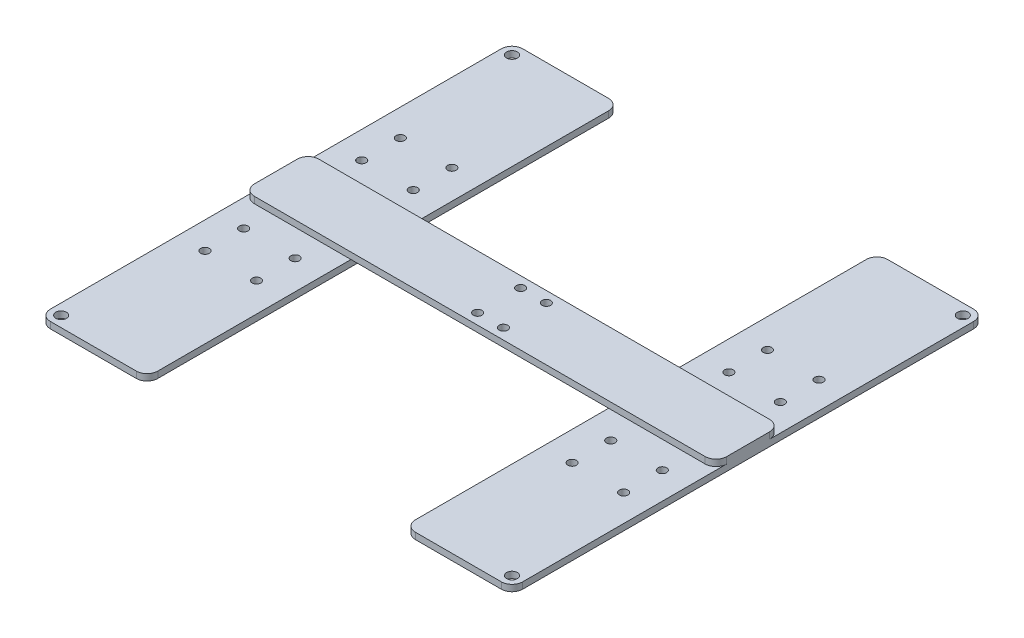
from build123d import *

# Parameters (mm, degrees)
SKETCH1_W           = 220
SKETCH1_H           = 30
BOSS_EXTRUDE1_DEPTH = 3
SKETCH2_W           = 50
SKETCH2_H           = 220
BOSS_EXTRUDE2_DEPTH = 3
SKETCH3_R           = 2.5
CUT_EXTRUDE1_DEPTH  = 3
FILLET1_R           = 5
CUT_EXTRUDE2_REACH  = 5
SKETCH4_R           = 2
CUT_EXTRUDE3_REACH  = 8
SKETCH5_R           = 2


with BuildPart() as part:
    # Sketch1 → Boss-Extrude1 (new body)
    with BuildSketch(Plane(origin=(0, 0, 0), x_dir=(1, 0, 0), z_dir=(0, 1, 0))):
        Rectangle(SKETCH1_W, SKETCH1_H)
    extrude(amount=BOSS_EXTRUDE1_DEPTH)

    # Sketch2 → Boss-Extrude2 (add)
    with BuildSketch(Plane.XZ):
        with Locations((-85, 0)):
            Rectangle(SKETCH2_W, SKETCH2_H)
        with Locations((85, 0)):
            Rectangle(SKETCH2_W, SKETCH2_H)
    extrude(amount=BOSS_EXTRUDE2_DEPTH)

    # Sketch3 → Cut-Extrude1 (cut)
    with BuildSketch(Plane(origin=(0, 0, 0), x_dir=(1, 0, 0), z_dir=(0, 1, 0))):
        with Locations((-105, 105)):
            Circle(SKETCH3_R)
        with Locations((105, 105)):
            Circle(SKETCH3_R)
        with Locations((105, -105)):
            Circle(SKETCH3_R)
        with Locations((-105, -105)):
            Circle(SKETCH3_R)
    extrude(amount=-CUT_EXTRUDE1_DEPTH, mode=Mode.SUBTRACT)

    # Fillet1
    fillet1_edges = [part.edges().sort_by_distance(p)[0] for p in [
        (-60, -1.5, -110),
        (-60, -1.5, 110),
        (-110, -1.5, 110),
        (-110, -1.5, -110),
        (110, -1.5, -110),
        (110, -1.5, 110),
        (60, -1.5, 110),
        (60, -1.5, -110),
        (110, 1.5, 15),
        (-110, 1.5, 15),
        (-110, 1.5, -15),
        (110, 1.5, -15),
    ]]
    fillet(fillet1_edges, radius=FILLET1_R)

    # Sketch4 → Cut-Extrude2 (cut, up to next)
    with BuildSketch(Plane(origin=(0, 0, 0), x_dir=(1, 0, 0), z_dir=(0, 1, 0)), mode=Mode.PRIVATE) as cut_extrude2_sk1:
        with Locations((-97.5, 27.5)):
            Circle(SKETCH4_R)
    cut_extrude2_tool1 = extrude(cut_extrude2_sk1.sketch, amount=-CUT_EXTRUDE2_REACH, mode=Mode.PRIVATE) & part.part
    add(cut_extrude2_tool1.solids().sort_by_distance((-97.5, 0, -27.5))[0], mode=Mode.SUBTRACT)
    # Sketch4 → Cut-Extrude2 (cut, up to next)
    with BuildSketch(Plane(origin=(0, 0, 0), x_dir=(1, 0, 0), z_dir=(0, 1, 0)), mode=Mode.PRIVATE) as cut_extrude2_sk2:
        with Locations((-73.5, 27.5)):
            Circle(SKETCH4_R)
    cut_extrude2_tool2 = extrude(cut_extrude2_sk2.sketch, amount=-CUT_EXTRUDE2_REACH, mode=Mode.PRIVATE) & part.part
    add(cut_extrude2_tool2.solids().sort_by_distance((-73.5, 0, -27.5))[0], mode=Mode.SUBTRACT)
    # Sketch4 → Cut-Extrude2 (cut, up to next)
    with BuildSketch(Plane(origin=(0, 0, 0), x_dir=(1, 0, 0), z_dir=(0, 1, 0)), mode=Mode.PRIVATE) as cut_extrude2_sk3:
        with Locations((-73.5, 45.5)):
            Circle(SKETCH4_R)
    cut_extrude2_tool3 = extrude(cut_extrude2_sk3.sketch, amount=-CUT_EXTRUDE2_REACH, mode=Mode.PRIVATE) & part.part
    add(cut_extrude2_tool3.solids().sort_by_distance((-73.5, 0, -45.5))[0], mode=Mode.SUBTRACT)
    # Sketch4 → Cut-Extrude2 (cut, up to next)
    with BuildSketch(Plane(origin=(0, 0, 0), x_dir=(1, 0, 0), z_dir=(0, 1, 0)), mode=Mode.PRIVATE) as cut_extrude2_sk4:
        with Locations((-97.5, 45.5)):
            Circle(SKETCH4_R)
    cut_extrude2_tool4 = extrude(cut_extrude2_sk4.sketch, amount=-CUT_EXTRUDE2_REACH, mode=Mode.PRIVATE) & part.part
    add(cut_extrude2_tool4.solids().sort_by_distance((-97.5, 0, -45.5))[0], mode=Mode.SUBTRACT)
    # Sketch4 → Cut-Extrude2 (cut, up to next)
    with BuildSketch(Plane(origin=(0, 0, 0), x_dir=(1, 0, 0), z_dir=(0, 1, 0)), mode=Mode.PRIVATE) as cut_extrude2_sk5:
        with Locations((97.5, 45.5)):
            Circle(SKETCH4_R)
    cut_extrude2_tool5 = extrude(cut_extrude2_sk5.sketch, amount=-CUT_EXTRUDE2_REACH, mode=Mode.PRIVATE) & part.part
    add(cut_extrude2_tool5.solids().sort_by_distance((97.5, 0, -45.5))[0], mode=Mode.SUBTRACT)
    # Sketch4 → Cut-Extrude2 (cut, up to next)
    with BuildSketch(Plane(origin=(0, 0, 0), x_dir=(1, 0, 0), z_dir=(0, 1, 0)), mode=Mode.PRIVATE) as cut_extrude2_sk6:
        with Locations((73.5, 45.5)):
            Circle(SKETCH4_R)
    cut_extrude2_tool6 = extrude(cut_extrude2_sk6.sketch, amount=-CUT_EXTRUDE2_REACH, mode=Mode.PRIVATE) & part.part
    add(cut_extrude2_tool6.solids().sort_by_distance((73.5, 0, -45.5))[0], mode=Mode.SUBTRACT)
    # Sketch4 → Cut-Extrude2 (cut, up to next)
    with BuildSketch(Plane(origin=(0, 0, 0), x_dir=(1, 0, 0), z_dir=(0, 1, 0)), mode=Mode.PRIVATE) as cut_extrude2_sk7:
        with Locations((73.5, 27.5)):
            Circle(SKETCH4_R)
    cut_extrude2_tool7 = extrude(cut_extrude2_sk7.sketch, amount=-CUT_EXTRUDE2_REACH, mode=Mode.PRIVATE) & part.part
    add(cut_extrude2_tool7.solids().sort_by_distance((73.5, 0, -27.5))[0], mode=Mode.SUBTRACT)
    # Sketch4 → Cut-Extrude2 (cut, up to next)
    with BuildSketch(Plane(origin=(0, 0, 0), x_dir=(1, 0, 0), z_dir=(0, 1, 0)), mode=Mode.PRIVATE) as cut_extrude2_sk8:
        with Locations((97.5, 27.5)):
            Circle(SKETCH4_R)
    cut_extrude2_tool8 = extrude(cut_extrude2_sk8.sketch, amount=-CUT_EXTRUDE2_REACH, mode=Mode.PRIVATE) & part.part
    add(cut_extrude2_tool8.solids().sort_by_distance((97.5, 0, -27.5))[0], mode=Mode.SUBTRACT)
    # Sketch4 → Cut-Extrude2 (cut, up to next)
    with BuildSketch(Plane(origin=(0, 0, 0), x_dir=(1, 0, 0), z_dir=(0, 1, 0)), mode=Mode.PRIVATE) as cut_extrude2_sk9:
        with Locations((97.5, -27.5)):
            Circle(SKETCH4_R)
    cut_extrude2_tool9 = extrude(cut_extrude2_sk9.sketch, amount=-CUT_EXTRUDE2_REACH, mode=Mode.PRIVATE) & part.part
    add(cut_extrude2_tool9.solids().sort_by_distance((97.5, 0, 27.5))[0], mode=Mode.SUBTRACT)
    # Sketch4 → Cut-Extrude2 (cut, up to next)
    with BuildSketch(Plane(origin=(0, 0, 0), x_dir=(1, 0, 0), z_dir=(0, 1, 0)), mode=Mode.PRIVATE) as cut_extrude2_sk10:
        with Locations((73.5, -27.5)):
            Circle(SKETCH4_R)
    cut_extrude2_tool10 = extrude(cut_extrude2_sk10.sketch, amount=-CUT_EXTRUDE2_REACH, mode=Mode.PRIVATE) & part.part
    add(cut_extrude2_tool10.solids().sort_by_distance((73.5, 0, 27.5))[0], mode=Mode.SUBTRACT)
    # Sketch4 → Cut-Extrude2 (cut, up to next)
    with BuildSketch(Plane(origin=(0, 0, 0), x_dir=(1, 0, 0), z_dir=(0, 1, 0)), mode=Mode.PRIVATE) as cut_extrude2_sk11:
        with Locations((73.5, -45.5)):
            Circle(SKETCH4_R)
    cut_extrude2_tool11 = extrude(cut_extrude2_sk11.sketch, amount=-CUT_EXTRUDE2_REACH, mode=Mode.PRIVATE) & part.part
    add(cut_extrude2_tool11.solids().sort_by_distance((73.5, 0, 45.5))[0], mode=Mode.SUBTRACT)
    # Sketch4 → Cut-Extrude2 (cut, up to next)
    with BuildSketch(Plane(origin=(0, 0, 0), x_dir=(1, 0, 0), z_dir=(0, 1, 0)), mode=Mode.PRIVATE) as cut_extrude2_sk12:
        with Locations((97.5, -45.5)):
            Circle(SKETCH4_R)
    cut_extrude2_tool12 = extrude(cut_extrude2_sk12.sketch, amount=-CUT_EXTRUDE2_REACH, mode=Mode.PRIVATE) & part.part
    add(cut_extrude2_tool12.solids().sort_by_distance((97.5, 0, 45.5))[0], mode=Mode.SUBTRACT)
    # Sketch4 → Cut-Extrude2 (cut, up to next)
    with BuildSketch(Plane(origin=(0, 0, 0), x_dir=(1, 0, 0), z_dir=(0, 1, 0)), mode=Mode.PRIVATE) as cut_extrude2_sk13:
        with Locations((-97.5, -45.5)):
            Circle(SKETCH4_R)
    cut_extrude2_tool13 = extrude(cut_extrude2_sk13.sketch, amount=-CUT_EXTRUDE2_REACH, mode=Mode.PRIVATE) & part.part
    add(cut_extrude2_tool13.solids().sort_by_distance((-97.5, 0, 45.5))[0], mode=Mode.SUBTRACT)
    # Sketch4 → Cut-Extrude2 (cut, up to next)
    with BuildSketch(Plane(origin=(0, 0, 0), x_dir=(1, 0, 0), z_dir=(0, 1, 0)), mode=Mode.PRIVATE) as cut_extrude2_sk14:
        with Locations((-73.5, -45.5)):
            Circle(SKETCH4_R)
    cut_extrude2_tool14 = extrude(cut_extrude2_sk14.sketch, amount=-CUT_EXTRUDE2_REACH, mode=Mode.PRIVATE) & part.part
    add(cut_extrude2_tool14.solids().sort_by_distance((-73.5, 0, 45.5))[0], mode=Mode.SUBTRACT)
    # Sketch4 → Cut-Extrude2 (cut, up to next)
    with BuildSketch(Plane(origin=(0, 0, 0), x_dir=(1, 0, 0), z_dir=(0, 1, 0)), mode=Mode.PRIVATE) as cut_extrude2_sk15:
        with Locations((-73.5, -27.5)):
            Circle(SKETCH4_R)
    cut_extrude2_tool15 = extrude(cut_extrude2_sk15.sketch, amount=-CUT_EXTRUDE2_REACH, mode=Mode.PRIVATE) & part.part
    add(cut_extrude2_tool15.solids().sort_by_distance((-73.5, 0, 27.5))[0], mode=Mode.SUBTRACT)
    # Sketch4 → Cut-Extrude2 (cut, up to next)
    with BuildSketch(Plane(origin=(0, 0, 0), x_dir=(1, 0, 0), z_dir=(0, 1, 0)), mode=Mode.PRIVATE) as cut_extrude2_sk16:
        with Locations((-97.5, -27.5)):
            Circle(SKETCH4_R)
    cut_extrude2_tool16 = extrude(cut_extrude2_sk16.sketch, amount=-CUT_EXTRUDE2_REACH, mode=Mode.PRIVATE) & part.part
    add(cut_extrude2_tool16.solids().sort_by_distance((-97.5, 0, 27.5))[0], mode=Mode.SUBTRACT)

    # Sketch5 → Cut-Extrude3 (cut, up to next)
    with BuildSketch(Plane(origin=(0, 3, 0), x_dir=(1, 0, 0), z_dir=(0, 1, 0)), mode=Mode.PRIVATE) as cut_extrude3_sk1:
        with Locations((-6, 10)):
            Circle(SKETCH5_R)
    cut_extrude3_tool1 = extrude(cut_extrude3_sk1.sketch, amount=-CUT_EXTRUDE3_REACH, mode=Mode.PRIVATE) & part.part
    add(cut_extrude3_tool1.solids().sort_by_distance((-6, 3, -10))[0], mode=Mode.SUBTRACT)
    # Sketch5 → Cut-Extrude3 (cut, up to next)
    with BuildSketch(Plane(origin=(0, 3, 0), x_dir=(1, 0, 0), z_dir=(0, 1, 0)), mode=Mode.PRIVATE) as cut_extrude3_sk2:
        with Locations((6, 10)):
            Circle(SKETCH5_R)
    cut_extrude3_tool2 = extrude(cut_extrude3_sk2.sketch, amount=-CUT_EXTRUDE3_REACH, mode=Mode.PRIVATE) & part.part
    add(cut_extrude3_tool2.solids().sort_by_distance((6, 3, -10))[0], mode=Mode.SUBTRACT)
    # Sketch5 → Cut-Extrude3 (cut, up to next)
    with BuildSketch(Plane(origin=(0, 3, 0), x_dir=(1, 0, 0), z_dir=(0, 1, 0)), mode=Mode.PRIVATE) as cut_extrude3_sk3:
        with Locations((6, -10)):
            Circle(SKETCH5_R)
    cut_extrude3_tool3 = extrude(cut_extrude3_sk3.sketch, amount=-CUT_EXTRUDE3_REACH, mode=Mode.PRIVATE) & part.part
    add(cut_extrude3_tool3.solids().sort_by_distance((6, 3, 10))[0], mode=Mode.SUBTRACT)
    # Sketch5 → Cut-Extrude3 (cut, up to next)
    with BuildSketch(Plane(origin=(0, 3, 0), x_dir=(1, 0, 0), z_dir=(0, 1, 0)), mode=Mode.PRIVATE) as cut_extrude3_sk4:
        with Locations((-6, -10)):
            Circle(SKETCH5_R)
    cut_extrude3_tool4 = extrude(cut_extrude3_sk4.sketch, amount=-CUT_EXTRUDE3_REACH, mode=Mode.PRIVATE) & part.part
    add(cut_extrude3_tool4.solids().sort_by_distance((-6, 3, 10))[0], mode=Mode.SUBTRACT)


solid = part.part
